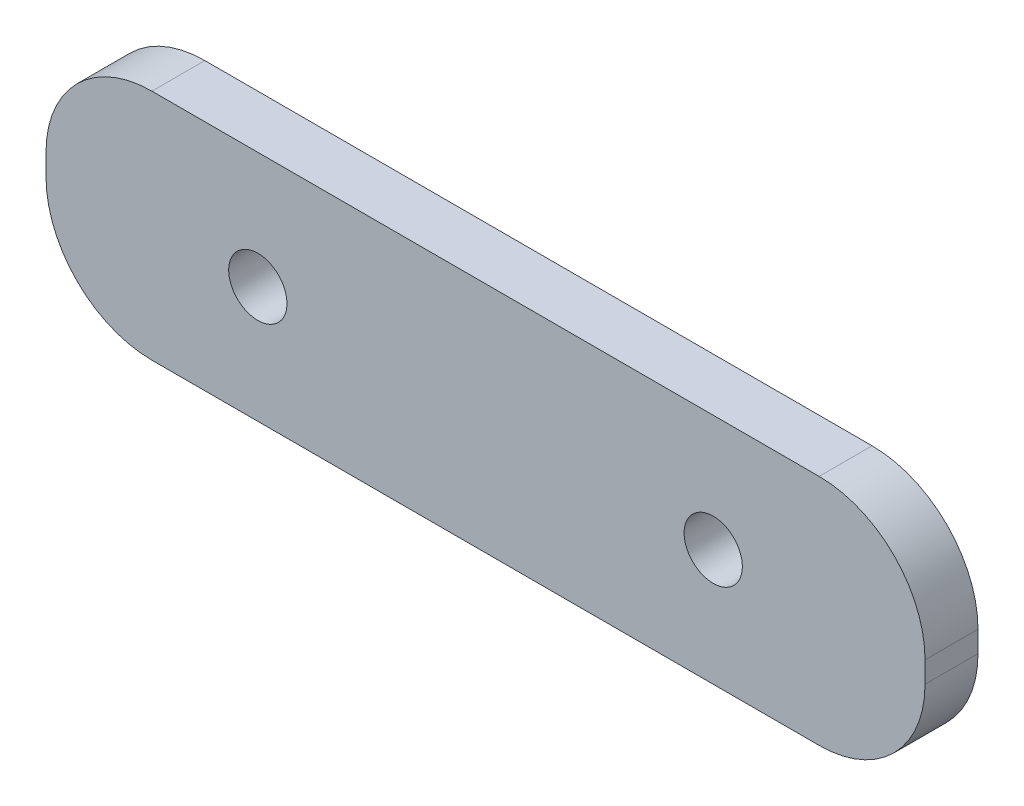
from build123d import *

# Parameters (mm, degrees)
SKETCH1_W            = 83
SKETCH1_H            = 67
BOSS_EXTRUDE1_DEPTH  = 5
M5_CLEARANCE_HOLE1_D = 5.5
M3_CLEARANCE_HOLE1_D = 3.4
SKETCH6_R            = 11.05
CUT_EXTRUDE1_DEPTH   = 6
FILLET1_R            = 10
SKETCH7_W            = 96.913580025
SKETCH7_H            = 48.46217056
CUT_EXTRUDE2_DEPTH   = 6
FILLET2_R            = 10


with BuildPart() as part:
    # Sketch1 → Boss-Extrude1 (new body)
    with BuildSketch(Plane.XY):
        Rectangle(SKETCH1_W, SKETCH1_H)
    extrude(amount=BOSS_EXTRUDE1_DEPTH)

    # M5 Clearance Hole1 (through all)
    with Locations(Plane.XY.offset(5)):
        with Locations((21.5, -22.5), (-21.5, -22.5)):
            Hole(M5_CLEARANCE_HOLE1_D / 2)

    # M3 Clearance Hole1 (through all)
    with Locations(Plane(origin=(0, 0, 0), x_dir=(-1, 0, 0), z_dir=(0, 0, -1))):
        with Locations((-32.041076253, 28.00000478), (-1.041076253, 28.00000478), (-1.041076253, -2.99999522), (-32.041076253, -2.99999522)):
            Hole(M3_CLEARANCE_HOLE1_D / 2)

    # Sketch6 → Cut-Extrude1 (cut, through all)
    with BuildSketch(Plane.XY.offset(5)):
        with Locations((16.541076624, 12.500005008)):
            Circle(SKETCH6_R)
    extrude(amount=-CUT_EXTRUDE1_DEPTH, mode=Mode.SUBTRACT)

    # Fillet1
    fillet1_edges = [part.edges().sort_by_distance(p)[0] for p in [
        (41.5, -33.5, 2.5),
        (-41.5, -33.5, 2.5),
        (-41.5, 33.5, 2.5),
        (41.5, 33.5, 2.5),
    ]]
    fillet(fillet1_edges, radius=FILLET1_R)

    # Sketch7 → Cut-Extrude2 (cut, through all)
    with BuildSketch(Plane.XY.offset(5)):
        with Locations((2.882260535, 12.73108528)):
            Rectangle(SKETCH7_W, SKETCH7_H)
    extrude(amount=-CUT_EXTRUDE2_DEPTH, mode=Mode.SUBTRACT)

    # Fillet2
    fillet2_edges = [part.edges().sort_by_distance(p)[0] for p in [
        (41.5, -11.5, 2.5),
        (-41.5, -11.5, 2.5),
    ]]
    fillet(fillet2_edges, radius=FILLET2_R)


solid = part.part
